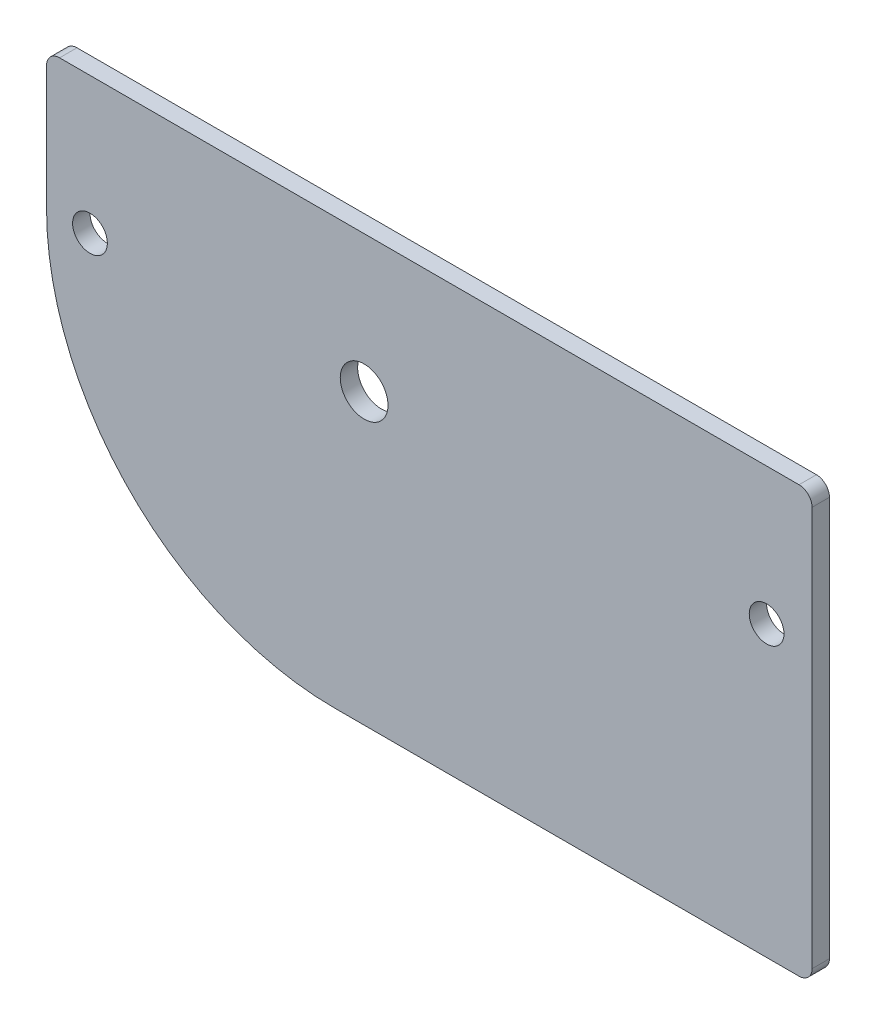
from build123d import *

# Parameters (mm, degrees)
SKETCH1_W           = 117.069701218
SKETCH1_H           = 60.929458134
BOSS_EXTRUDE1_DEPTH = 2
SKETCH3_R           = 2
SKETCH3_R_2         = 2.75
CUT_EXTRUDE1_DEPTH  = 3


with BuildPart() as part:
    # Sketch1 → Boss-Extrude1 (new body)
    with BuildSketch(Plane.XY):
        Rectangle(SKETCH1_W, SKETCH1_H)
    extrude(amount=BOSS_EXTRUDE1_DEPTH)

    # Sketch3 → Cut-Extrude1 (cut, through all)
    with BuildSketch(Plane(origin=(0, 0, 0), x_dir=(-1, 0, 0), z_dir=(0, 0, -1))):
        with Locations((-24.357544508, 2.794584929)):
            Circle(SKETCH3_R)
        with Locations((53.534850609, 2.794584929)):
            Circle(SKETCH3_R)
        with Locations((21.97485305, 2.79526544)):
            Circle(SKETCH3_R_2)
        with BuildLine():
            Line((25.349937795, -30.464729067), (25.349937795, -36.756710317))
            Line((25.349937795, -36.756710317), (60.494221028, -36.756710317))
            Line((60.494221028, -36.756710317), (60.494221028, 2.79526544))
            Line((60.494221028, 2.79526544), (58.534850609, 2.79526544))
            ThreePointArc((58.534850609, 2.79526544), (48.841775064, -20.718537892), (25.349937795, -30.464729067))
        make_face()
        with BuildLine():
            Line((-29.591361368, 17.035270933), (-29.591361368, -28.964729067))
            ThreePointArc((-29.591361368, -28.964729067), (-29.15202154, -30.025389239), (-28.091361368, -30.464729067))
            Line((-28.091361368, -30.464729067), (-58.534850609, -30.464729067))
            Line((-58.534850609, -30.464729067), (-58.534850609, 30.464729067))
            Line((-58.534850609, 30.464729067), (58.534850609, 30.464729067))
            Line((58.534850609, 30.464729067), (58.534850609, 17.035270933))
            ThreePointArc((58.534850609, 17.035270933), (58.095510781, 18.095931105), (57.034850609, 18.535270933))
            Line((57.034850609, 18.535270933), (-28.091361368, 18.535270933))
            ThreePointArc((-28.091361368, 18.535270933), (-29.15202154, 18.095931105), (-29.591361368, 17.035270933))
        make_face()
    extrude(amount=-CUT_EXTRUDE1_DEPTH, mode=Mode.SUBTRACT)


solid = part.part
